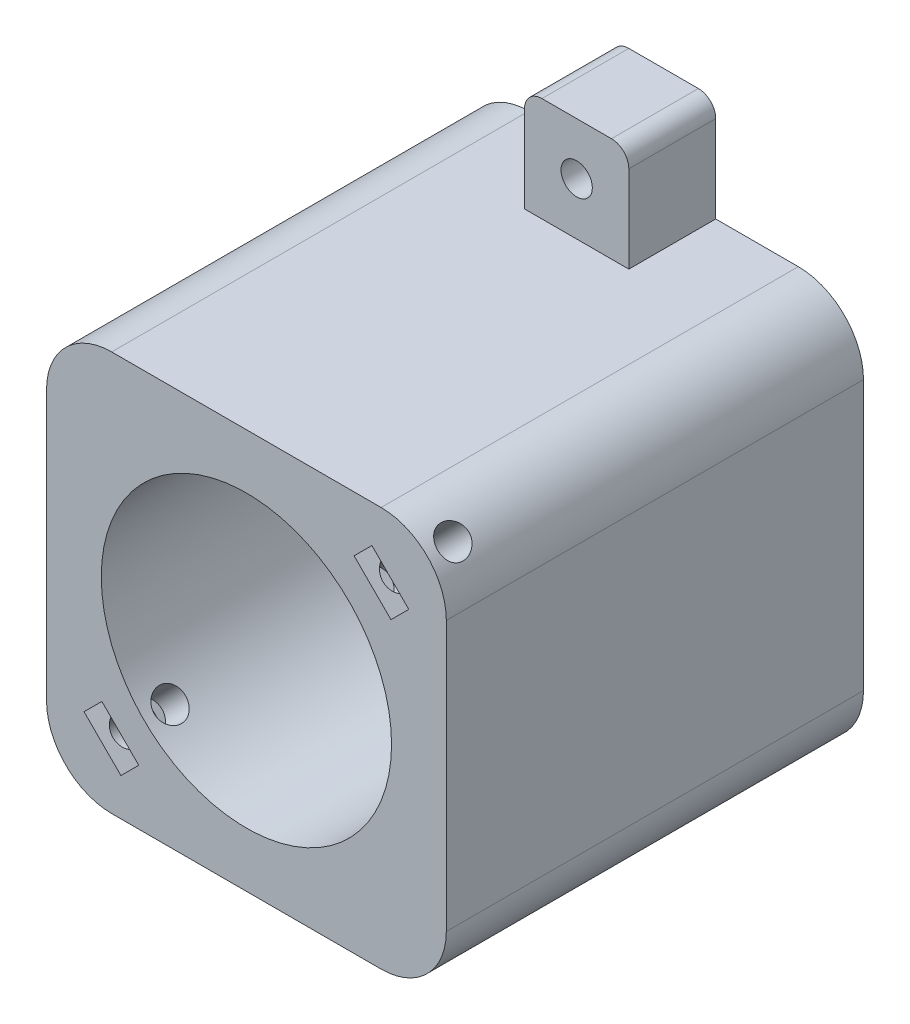
from build123d import *

# Parameters (mm, degrees)
MAIN_DEPTH           = 48
SKETCH2_R            = 16.7
MOTOR_HOLE_DEPTH     = 49
PULLEY_OUT_REACH     = 48
SKETCH3_W            = 10
SKETCH3_H            = 30
NUTS_DEPTH           = 6
M3_CLEARANCE_HOLE1_D = 3.6
BOSS_EXTRUDE2_DEPTH  = 10
M3_CLEARANCE_HOLE2_D = 3.6


with BuildPart() as part:
    # Sketch1 → Main (new body)
    with BuildSketch(Plane.XY):
        with BuildLine():
            Line((-15.5, 23), (15.5, 23))
            ThreePointArc((15.5, 23), (20.803300859, 20.803300859), (23, 15.5))
            Line((23, 15.5), (23, -15.5))
            ThreePointArc((23, -15.5), (20.803300859, -20.803300859), (15.5, -23))
            Line((15.5, -23), (-15.5, -23))
            ThreePointArc((-15.5, -23), (-20.803300859, -20.803300859), (-23, -15.5))
            Line((-23, -15.5), (-23, 15.5))
            ThreePointArc((-23, 15.5), (-20.803300859, 20.803300859), (-15.5, 23))
        make_face()
    extrude(amount=MAIN_DEPTH)

    # Sketch2 → Motor Hole (cut, through all)
    with BuildSketch(Plane(origin=(0, 0, 0), x_dir=(-1, 0, 0), z_dir=(0, 0, -1))):
        Circle(SKETCH2_R)
    extrude(amount=-MOTOR_HOLE_DEPTH, mode=Mode.SUBTRACT)

    # Sketch3 → Pulley Out (cut, up to next)
    with BuildSketch(Plane.ZY.offset(23), mode=Mode.PRIVATE) as pulley_out_sk1:
        with Locations((12, 0)):
            Rectangle(SKETCH3_W, SKETCH3_H)
    pulley_out_tool1 = extrude(pulley_out_sk1.sketch, amount=-PULLEY_OUT_REACH, mode=Mode.PRIVATE) & part.part
    add(pulley_out_tool1.solids().sort_by_distance((-23, 0, 12))[0], mode=Mode.SUBTRACT)

    # Sketch9 → Nuts (cut)
    with BuildSketch(Plane.XY.offset(48)):
        Polygon((-18.681980515, -14.439339828), (-16.63137085, -12.388730163), (-12.388730163, -16.63137085), (-14.439339828, -18.681980515), align=None)
        Polygon((18.681980515, 14.439339828), (16.63137085, 12.388730163), (12.388730163, 16.63137085), (14.439339828, 18.681980515), align=None)
    extrude(amount=-NUTS_DEPTH, mode=Mode.SUBTRACT)

    # M3 Clearance Hole1 (through all)
    with Locations(Plane(origin=(-20.803300859, -20.803300859, 45), x_dir=(-0.707106781, 0.707106781, 0), z_dir=(-0.707106781, -0.707106781, 0))):
        with Locations((0, 0)):
            Hole(M3_CLEARANCE_HOLE1_D / 2)

    # Sketch15 → Boss-Extrude2 (add)
    with BuildSketch(Plane(origin=(0, 0, 0), x_dir=(-1, 0, 0), z_dir=(0, 0, -1))):
        with BuildLine():
            Line((-6, -23), (6, -23))
            Line((6, -23), (6, -33))
            ThreePointArc((6, -33), (5.414213562, -34.414213562), (4, -35))
            Line((4, -35), (-4, -35))
            ThreePointArc((-4, -35), (-5.414213562, -34.414213562), (-6, -33))
            Line((-6, -33), (-6, -23))
        make_face()
        with BuildLine():
            Line((-4, 35), (4, 35))
            ThreePointArc((4, 35), (5.414213562, 34.414213562), (6, 33))
            Line((6, 33), (6, 23))
            Line((6, 23), (-6, 23))
            Line((-6, 23), (-6, 33))
            ThreePointArc((-6, 33), (-5.414213562, 34.414213562), (-4, 35))
        make_face()
    extrude(amount=-BOSS_EXTRUDE2_DEPTH)

    # M3 Clearance Hole2 (through all)
    with Locations(Plane(origin=(0, 0, 0), x_dir=(-1, 0, 0), z_dir=(0, 0, -1))):
        with Locations((0, -29), (0, 29)):
            Hole(M3_CLEARANCE_HOLE2_D / 2)


solid = part.part
